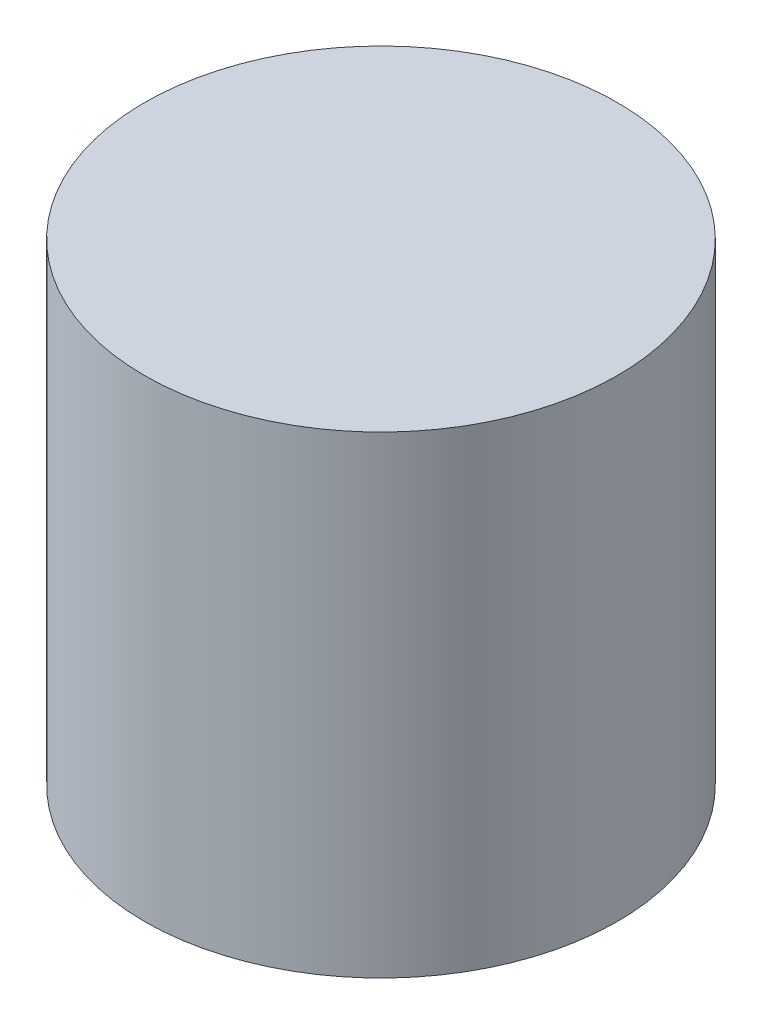
from build123d import *

# Parameters (mm, degrees)
SKETCH1_R           = 63.5
BOSS_EXTRUDE1_DEPTH = 127


with BuildPart() as part:
    # Sketch1 → Boss-Extrude1 (new body)
    with BuildSketch(Plane(origin=(0, 0, 0), x_dir=(1, 0, 0), z_dir=(0, 1, 0))):
        with Locations((-59.749366975, 21.051590437)):
            Circle(SKETCH1_R)
    extrude(amount=BOSS_EXTRUDE1_DEPTH)


solid = part.part
